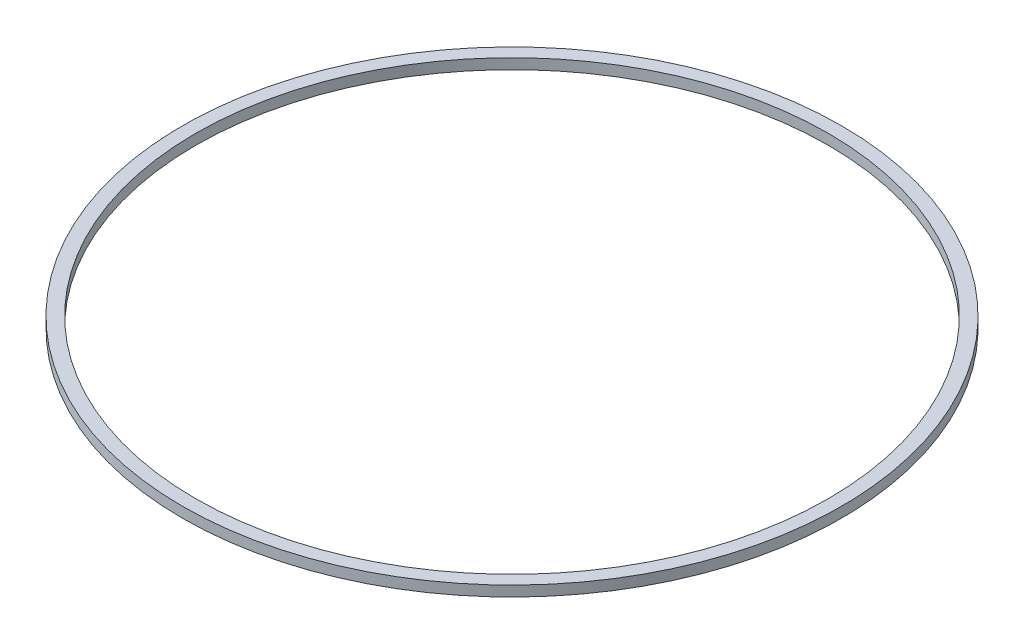
from build123d import *

# Parameters (mm, degrees)
SKETCH1_R           = 63.5
SKETCH1_R_2         = 60.96
BOSS_EXTRUDE1_DEPTH = 1


with BuildPart() as part:
    # Sketch1 → Boss-Extrude1 (new body, symmetric)
    with BuildSketch(Plane(origin=(0, 0, 0), x_dir=(1, 0, 0), z_dir=(0, 1, 0))):
        Circle(SKETCH1_R)
        Circle(SKETCH1_R_2, mode=Mode.SUBTRACT)
    extrude(amount=BOSS_EXTRUDE1_DEPTH, both=True)


solid = part.part
